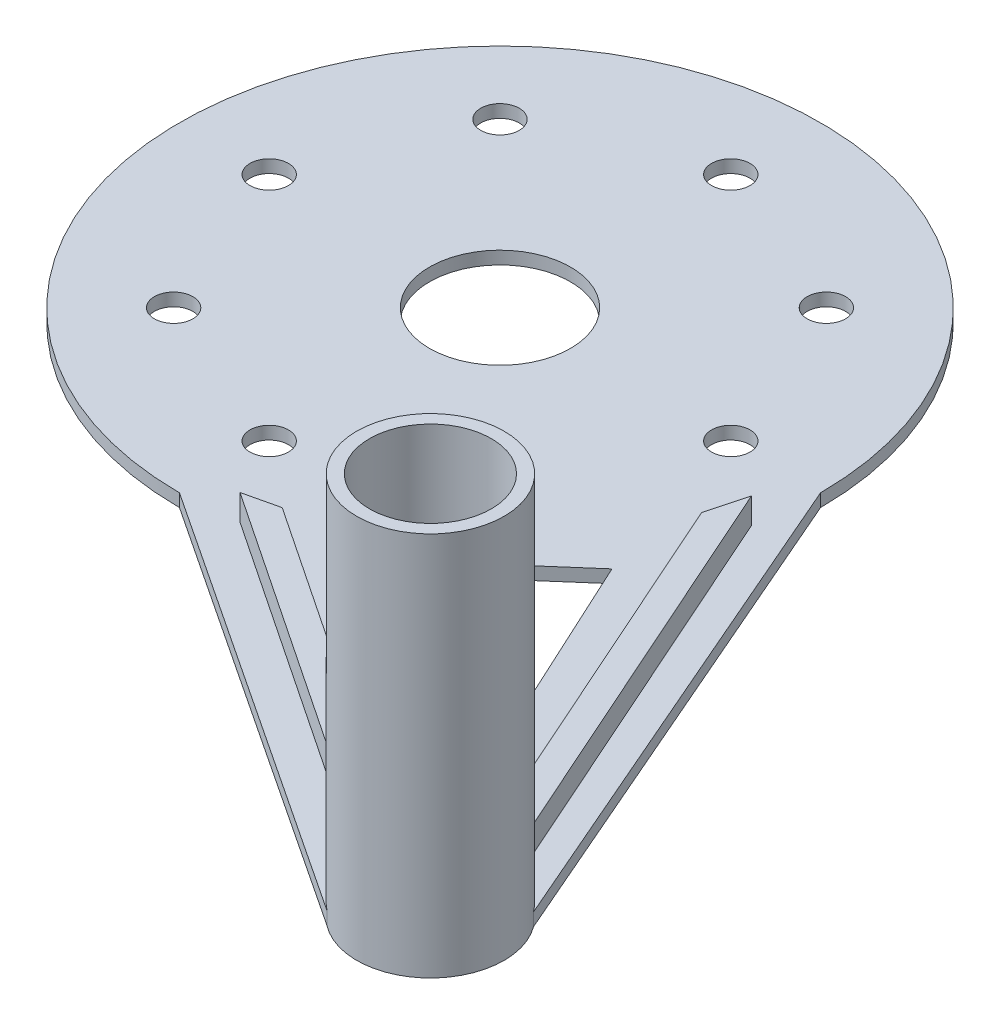
from build123d import *

# Parameters (mm, degrees)
SKETCH_1_R          = 5.75
EXTRUDE_1_DEPTH     = 1
SKETCH_1_R_2        = 25
SKETCH_1_R_3        = 1.5
SKETCH_1_R_4        = 5.5
EXTRUDE_1_2_DEPTH   = 1
EXTRUDE_2_DEPTH     = 1
SKETCH_3_R          = 5.75
EXTRUDE_3_DEPTH     = 30
CUT_EXTRUDE_1_DEPTH = 30
EXTRUDE_4_DEPTH     = 2
SKETCH_6_R          = 4.75
CUT_EXTRUDE_3_DEPTH = 30


with BuildPart() as part:
    # 草图1 → 凸台-拉伸1 (new body)
    with BuildSketch(Plane(origin=(0, 0, 0), x_dir=(1, 0, 0), z_dir=(0, 1, 0))):
        with Locations((37.5, -42.927264064)):
            Circle(SKETCH_1_R)
    extrude(amount=EXTRUDE_1_DEPTH)



with BuildPart() as body_2:
    # 草图1 → Extrude 1 2 (new body)
    with BuildSketch(Plane(origin=(0, 0, 0), x_dir=(1, 0, 0), z_dir=(0, 1, 0))):
        Circle(SKETCH_1_R_2)
        with Locations((0, -18)):
            Circle(SKETCH_1_R_3, mode=Mode.SUBTRACT)
        with Locations((-12.727922061, -12.727922061)):
            Circle(SKETCH_1_R_3, mode=Mode.SUBTRACT)
        with Locations((-18, 0)):
            Circle(SKETCH_1_R_3, mode=Mode.SUBTRACT)
        with Locations((-12.727922061, 12.727922061)):
            Circle(SKETCH_1_R_3, mode=Mode.SUBTRACT)
        with Locations((0, 18)):
            Circle(SKETCH_1_R_3, mode=Mode.SUBTRACT)
        with Locations((12.727922061, 12.727922061)):
            Circle(SKETCH_1_R_3, mode=Mode.SUBTRACT)
        with Locations((18, 0)):
            Circle(SKETCH_1_R_3, mode=Mode.SUBTRACT)
        with Locations((12.727922061, -12.727922061)):
            Circle(SKETCH_1_R_3, mode=Mode.SUBTRACT)
        Circle(SKETCH_1_R_4, mode=Mode.SUBTRACT)
    extrude(amount=EXTRUDE_1_2_DEPTH)


with BuildPart() as part_1:
    add(part.part)

    add(body_2.part)  # 凸台-拉伸2 merges body 2
    # 草图2 → 凸台-拉伸2 (add)
    with BuildSketch(Plane(origin=(0, 0, 0), x_dir=(1, 0, 0), z_dir=(0, 1, 0))):
        with BuildLine():
            Line((0, -25), (33.976022053, -47.470839685))
            ThreePointArc((33.976022053, -47.470839685), (37.308300147, -42.73151924), (42.116158776, -39.498914876))
            Line((42.116158776, -39.498914876), (25, 0))
            Line((25, 0), (15.739254024, -17.717074967))
            Line((15.739254024, -17.717074967), (0, -25))
        make_face()
    extrude(amount=EXTRUDE_2_DEPTH)

    # 草图3 → 凸台-拉伸3 (add)
    with BuildSketch(Plane(origin=(0, 0, 0), x_dir=(1, 0, 0), z_dir=(0, 1, 0))):
        with Locations((37.5, -42.927264064)):
            Circle(SKETCH_3_R)
    extrude(amount=EXTRUDE_3_DEPTH)

    # 草图4 → 切除-拉伸1 (cut)
    with BuildSketch(Plane(origin=(0, 1, 0), x_dir=(1, 0, 0), z_dir=(0, 1, 0))):
        Polygon((16.101209637, -18.431490076), (22.006815823, -13.272525562), (33.717105263, -38.596882163), (10.14517855, -23.634504306), align=None)
    extrude(amount=-CUT_EXTRUDE_1_DEPTH, mode=Mode.SUBTRACT)

    # 草图5 → 凸台-拉伸4 (add)
    with BuildSketch(Plane(origin=(0, 1, 0), x_dir=(1, 0, 0), z_dir=(0, 1, 0))):
        Polygon((31.75, -42.927264064), (4.342000799, -24.620053393), (7.010063543, -23.99706251), (32.159659881, -40.79576989), align=None)
        Polygon((38.971739634, -37.368803625), (24.515251473, -4.899229044), (23.694530655, -7.973030605), (36.720800315, -37.230304537), align=None)
    extrude(amount=EXTRUDE_4_DEPTH)

    # 草图6 → 切除-拉伸3 (cut)
    with BuildSketch(Plane(origin=(0, 30, 0), x_dir=(1, 0, 0), z_dir=(0, 1, 0))):
        with Locations((37.5, -42.927264064)):
            Circle(SKETCH_6_R)
    extrude(amount=-CUT_EXTRUDE_3_DEPTH, mode=Mode.SUBTRACT)


solid = part_1.part
